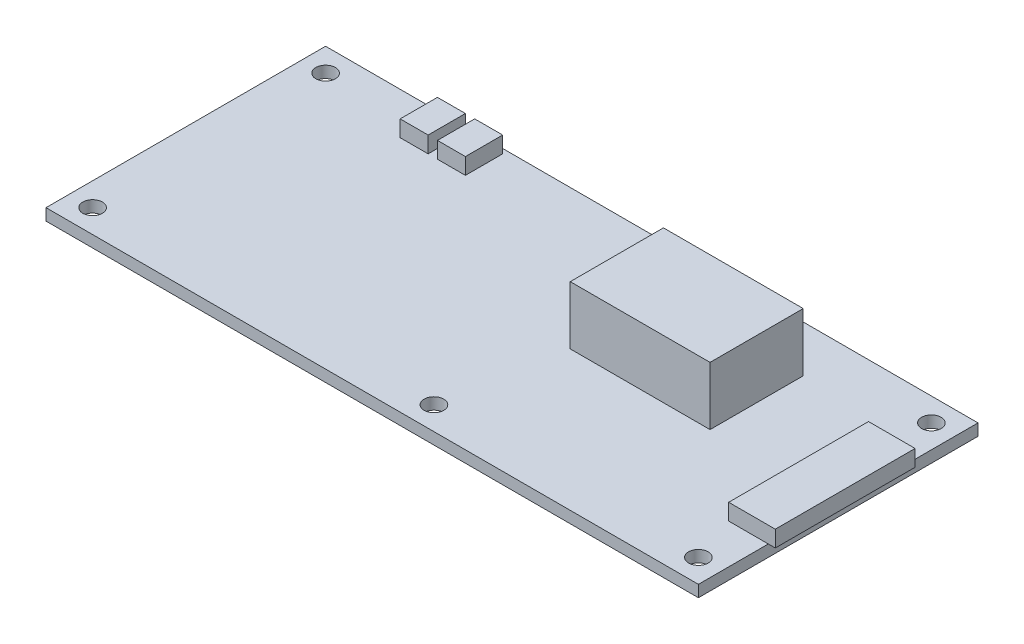
from build123d import *

# Parameters (mm, degrees)
SKETCH2_W           = 140
SKETCH2_H           = 60
SKETCH2_R           = 2.1
BOSS_EXTRUDE1_DEPTH = 2.5
SKETCH3_W           = 6
SKETCH3_H           = 8
SKETCH3_W_2         = 10
SKETCH3_H_2         = 30
BOSS_EXTRUDE2_DEPTH = 3.5
SKETCH4_W           = 30
SKETCH4_H           = 20
BOSS_EXTRUDE3_DEPTH = 12.5


with BuildPart() as part:
    # Sketch2 → Boss-Extrude1 (new body)
    with BuildSketch(Plane(origin=(0, 0, 0), x_dir=(1, 0, 0), z_dir=(0, 1, 0))):
        Rectangle(SKETCH2_W, SKETCH2_H)
        with Locations((-65, 25)):
            Circle(SKETCH2_R, mode=Mode.SUBTRACT)
        with Locations((8.25, 25)):
            Circle(SKETCH2_R, mode=Mode.SUBTRACT)
        with Locations((65, 25)):
            Circle(SKETCH2_R, mode=Mode.SUBTRACT)
        with Locations((-65, -25)):
            Circle(SKETCH2_R, mode=Mode.SUBTRACT)
        with Locations((8.25, -25)):
            Circle(SKETCH2_R, mode=Mode.SUBTRACT)
        with Locations((65, -25)):
            Circle(SKETCH2_R, mode=Mode.SUBTRACT)
    extrude(amount=BOSS_EXTRUDE1_DEPTH)

    # Sketch3 → Boss-Extrude2 (add)
    with BuildSketch(Plane(origin=(0, 2.5, 0), x_dir=(1, 0, 0), z_dir=(0, 1, 0))):
        with Locations((-42, 25)):
            Rectangle(SKETCH3_W, SKETCH3_H)
        with Locations((-34, 25)):
            Rectangle(SKETCH3_W, SKETCH3_H)
        with Locations((66.5, 0)):
            Rectangle(SKETCH3_W_2, SKETCH3_H_2)
    extrude(amount=BOSS_EXTRUDE2_DEPTH)

    # Sketch4 → Boss-Extrude3 (add)
    with BuildSketch(Plane(origin=(0, 2.5, 0), x_dir=(1, 0, 0), z_dir=(0, 1, 0))):
        with Locations((27.5, 10)):
            Rectangle(SKETCH4_W, SKETCH4_H)
    extrude(amount=BOSS_EXTRUDE3_DEPTH)


solid = part.part
